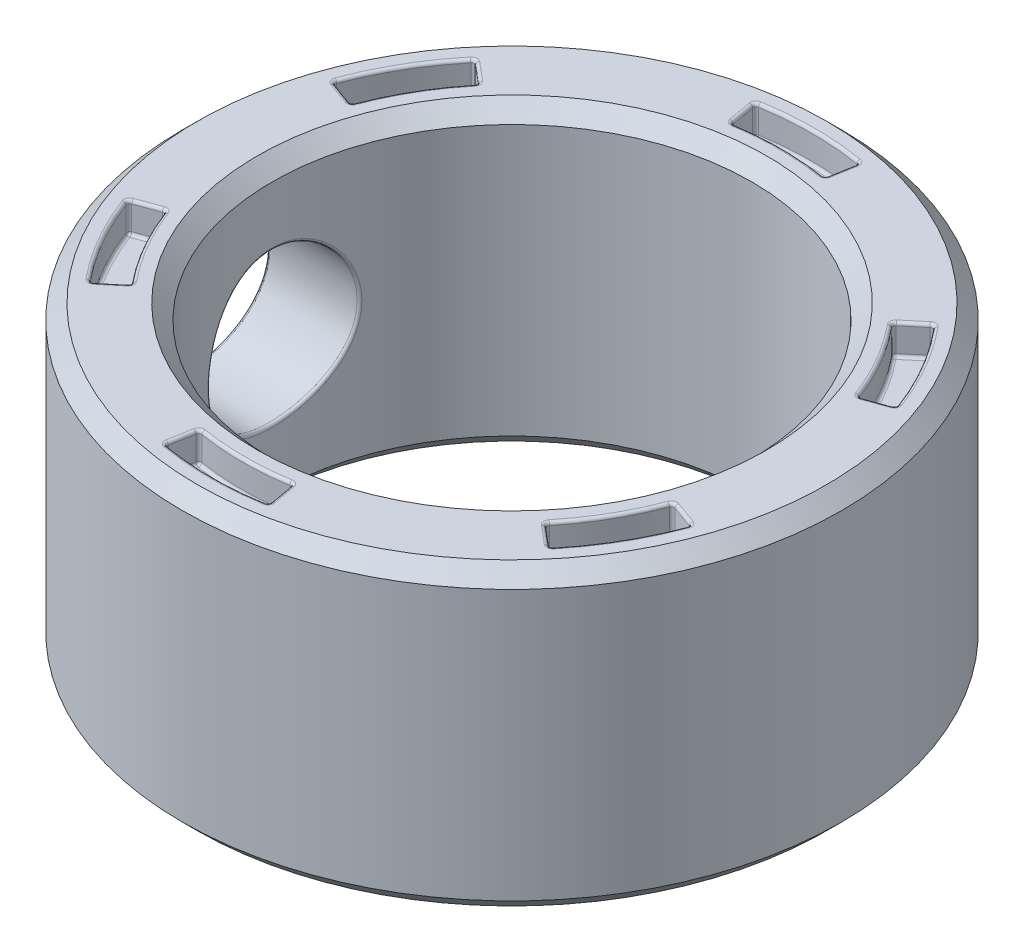
from build123d import *

# Parameters (mm, degrees)
SKETCH1_R                = 11
SKETCH1_R_2              = 8
BOSS_EXTRUDE1_DEPTH      = 10
CHAMFER1_SIZE            = 0.5
CUT_EXTRUDE1_DEPTH       = 1
FILLET1_R                = 0.1
CIRPATTERN1_COUNT        = 6
FILLET1_OF_CIRPATTERN1_R = 0.1
CUT_EXTRUDE2_REACH       = 13
SKETCH3_R                = 2.5
FILLET2_R                = 0.1


with BuildPart() as part:
    # Sketch1 → Boss-Extrude1 (new body)
    with BuildSketch(Plane(origin=(0, 0, 0), x_dir=(1, 0, 0), z_dir=(0, 1, 0))):
        Circle(SKETCH1_R)
        Circle(SKETCH1_R_2, mode=Mode.SUBTRACT)
    extrude(amount=BOSS_EXTRUDE1_DEPTH)

    # Chamfer1
    chamfer1_edges = [part.edges().sort_by_distance(p)[0] for p in [
        (-11, 0, 0),
        (-11, 10, 0),
        (-8, 0, 0),
        (-8, 10, 0),
    ]]
    chamfer(chamfer1_edges, length=CHAMFER1_SIZE)

    # Sketch2 → Cut-Extrude1 (cut)
    with BuildSketch(Plane(origin=(0, 10, 0), x_dir=(1, 0, 0), z_dir=(0, 1, 0))):
        with BuildLine():
            Line((-1.736481777, 9.84807753), (-1.562833599, 8.863269777))
            ThreePointArc((-1.562833599, 8.863269777), (0, 9), (1.562833599, 8.863269777))
            Line((1.562833599, 8.863269777), (1.736481777, 9.84807753))
            ThreePointArc((1.736481777, 9.84807753), (0, 10), (-1.736481777, 9.84807753))
        make_face()
    cut_extrude1 = extrude(amount=-CUT_EXTRUDE1_DEPTH, mode=Mode.SUBTRACT)

    # Fillet1
    fillet1_edges = [part.edges().sort_by_distance(p)[0] for p in [
        (0, 9, -10),
        (-1.736481777, 9.5, -9.84807753),
        (1.649657688, 9, -9.355673654),
        (1.736481777, 9.5, -9.84807753),
        (0, 9, -9),
        (1.562833599, 9.5, -8.863269777),
        (-1.649657688, 9, -9.355673654),
        (-1.562833599, 9.5, -8.863269777),
        (0, 10, -10),
        (-1.649657688, 10, -9.355673654),
        (0, 10, -9),
        (1.649657688, 10, -9.355673654),
    ]]
    fillet(fillet1_edges, radius=FILLET1_R)

    # CirPattern1: Cut-Extrude1 ×6 about axis
    cirpattern1_axis = Axis((0, 0, 0), (0, 1, 0))
    for i in range(1, CIRPATTERN1_COUNT):
        add(cut_extrude1.rotate(cirpattern1_axis, i * 360 / CIRPATTERN1_COUNT), mode=Mode.SUBTRACT)

    # Fillet1 of CirPattern1
    fillet1_of_cirpattern1_edges = [part.edges().sort_by_distance(p)[0] for p in [
        (-8.660254038, 9, -5),
        (-9.396926208, 9.5, -3.420201433),
        (-7.27742221, 9, -6.106482292),
        (-7.660444431, 9.5, -6.427876097),
        (-7.794228634, 9, -4.5),
        (-6.894399988, 9.5, -5.785088487),
        (-8.927079897, 9, -3.249191362),
        (-8.457233587, 9.5, -3.07818129),
        (-8.660254038, 10, -5),
        (-8.927079897, 10, -3.249191362),
        (-7.794228634, 10, -4.5),
        (-7.27742221, 10, -6.106482292),
        (-8.660254038, 9, 5),
        (-7.660444431, 9.5, 6.427876097),
        (-8.927079897, 9, 3.249191362),
        (-9.396926208, 9.5, 3.420201433),
        (-7.794228634, 9, 4.5),
        (-8.457233587, 9.5, 3.07818129),
        (-7.27742221, 9, 6.106482292),
        (-6.894399988, 9.5, 5.785088487),
        (-8.660254038, 10, 5),
        (-7.27742221, 10, 6.106482292),
        (-7.794228634, 10, 4.5),
        (-8.927079897, 10, 3.249191362),
        (0, 9, 10),
        (1.736481777, 9.5, 9.84807753),
        (-1.649657688, 9, 9.355673654),
        (-1.736481777, 9.5, 9.84807753),
        (0, 9, 9),
        (-1.562833599, 9.5, 8.863269777),
        (1.649657688, 9, 9.355673654),
        (1.562833599, 9.5, 8.863269777),
        (0, 10, 10),
        (1.649657688, 10, 9.355673654),
        (0, 10, 9),
        (-1.649657688, 10, 9.355673654),
        (8.660254038, 9, 5),
        (9.396926208, 9.5, 3.420201433),
        (7.27742221, 9, 6.106482292),
        (7.660444431, 9.5, 6.427876097),
        (7.794228634, 9, 4.5),
        (6.894399988, 9.5, 5.785088487),
        (8.927079897, 9, 3.249191362),
        (8.457233587, 9.5, 3.07818129),
        (8.660254038, 10, 5),
        (8.927079897, 10, 3.249191362),
        (7.794228634, 10, 4.5),
        (7.27742221, 10, 6.106482292),
        (8.660254038, 9, -5),
        (7.660444431, 9.5, -6.427876097),
        (8.927079897, 9, -3.249191362),
        (9.396926208, 9.5, -3.420201433),
        (7.794228634, 9, -4.5),
        (8.457233587, 9.5, -3.07818129),
        (7.27742221, 9, -6.106482292),
        (6.894399988, 9.5, -5.785088487),
        (8.660254038, 10, -5),
        (7.27742221, 10, -6.106482292),
        (7.794228634, 10, -4.5),
        (8.927079897, 10, -3.249191362),
    ]]
    fillet(fillet1_of_cirpattern1_edges, radius=FILLET1_OF_CIRPATTERN1_R)

    # Sketch3 → Cut-Extrude2 (cut, up to next)
    with BuildSketch(Plane(origin=(0, 0, 0), x_dir=(0, 0, -1), z_dir=(1, 0, 0)), mode=Mode.PRIVATE) as cut_extrude2_sk1:
        with Locations((0, 5)):
            Circle(SKETCH3_R)
    cut_extrude2_tool1 = extrude(cut_extrude2_sk1.sketch, amount=-CUT_EXTRUDE2_REACH, mode=Mode.PRIVATE) & part.part
    add(cut_extrude2_tool1.solids().sort_by_distance((0, 5, 0))[0], mode=Mode.SUBTRACT)

    # Fillet2
    fillet2_edges = [part.edges().sort_by_distance(p)[0] for p in [
        (-7.599342077, 5, 2.5),
        (-10.712142643, 5, 2.5),
    ]]
    fillet(fillet2_edges, radius=FILLET2_R)


solid = part.part
